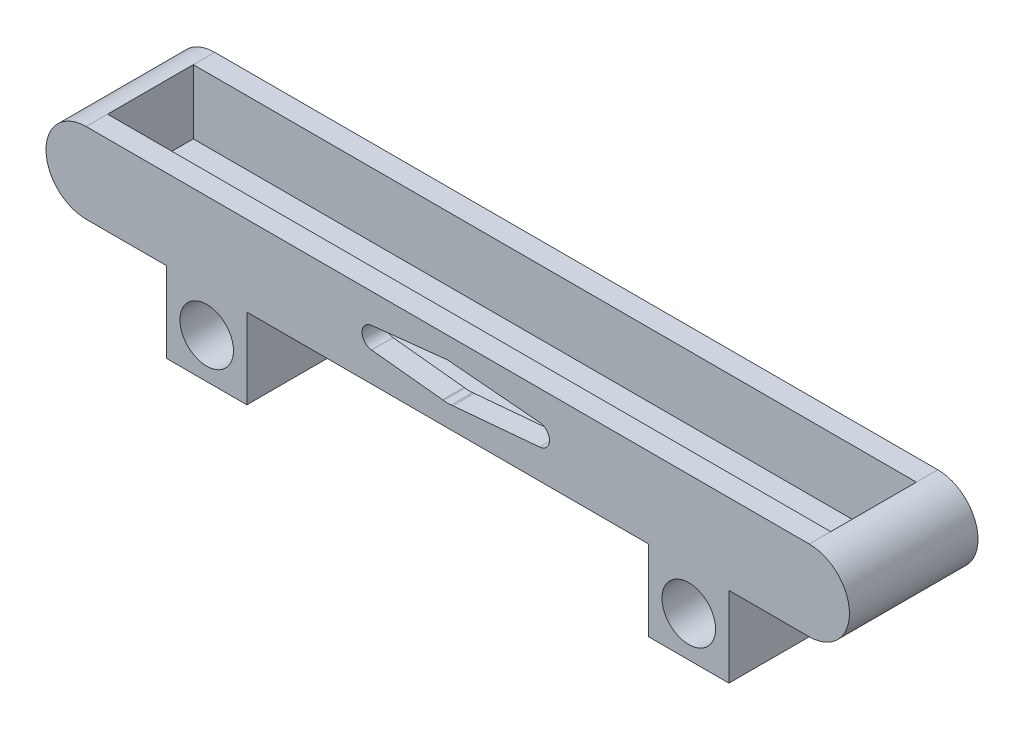
from build123d import *

# Parameters (mm, degrees)
SKETCH1_R           = 5
BOSS_EXTRUDE1_DEPTH = 4
BOSS_EXTRUDE2_START = -20
SKETCH1_4_R         = 5
BOSS_EXTRUDE2_DEPTH = 20
SKETCH2_W           = 135
SKETCH2_H           = 16
CUT_EXTRUDE1_DEPTH  = 12


with BuildPart() as part:
    # Sketch1 → Boss-Extrude1 (new body)
    with BuildSketch(Plane.XY):
        with BuildLine():
            Line((52.5, -7.5), (67.5, -7.5))
            ThreePointArc((67.5, -7.5), (75, 0), (67.5, 7.5))
            Line((67.5, 7.5), (-67.5, 7.5))
            ThreePointArc((-67.5, 7.5), (-75, 0), (-67.5, -7.5))
            Line((-67.5, -7.5), (-52.5, -7.5))
            Line((-52.5, -7.5), (-52.5, -22.5))
            Line((-52.5, -22.5), (-37.5, -22.5))
            Line((-37.5, -22.5), (-37.5, -7.5))
            Line((-37.5, -7.5), (37.5, -7.5))
            Line((37.5, -7.5), (37.5, -22.5))
            Line((37.5, -22.5), (52.5, -22.5))
            Line((52.5, -22.5), (52.5, -7.5))
        make_face()
        with BuildLine():
            Line((-14.211482552, 1.988787352), (-0.965077795, 3.3973761))
            ThreePointArc((-0.965077795, 3.3973761), (-0.860540111, 3.407937274), (-0.755897232, 3.417399505))
            ThreePointArc((-0.755897232, 3.417399505), (-0.049360306, 3.49965192), (0.65921534, 3.437358744))
            ThreePointArc((0.65921534, 3.437358744), (0.81309385, 3.427430851), (0.966800983, 3.415131426))
            Line((0.966800983, 3.415131426), (17.174893203, 1.992338417))
            ThreePointArc((17.174893203, 1.992338417), (19, 0), (17.174893203, -1.992338417))
            Line((17.174893203, -1.992338417), (0.966800983, -3.415131426))
            ThreePointArc((0.966800983, -3.415131426), (0.81309385, -3.427430851), (0.65921534, -3.437358744))
            ThreePointArc((0.65921534, -3.437358744), (-0.049360306, -3.49965192), (-0.755897232, -3.417399505))
            ThreePointArc((-0.755897232, -3.417399505), (-0.860540111, -3.407937274), (-0.965077795, -3.3973761))
            Line((-0.965077795, -3.3973761), (-14.211482552, -1.988787352))
            ThreePointArc((-14.211482552, -1.988787352), (-16, 0), (-14.211482552, 1.988787352))
        make_face(mode=Mode.SUBTRACT)
        with Locations((45, -15)):
            Circle(SKETCH1_R, mode=Mode.SUBTRACT)
        with Locations((-45, -15)):
            Circle(SKETCH1_R, mode=Mode.SUBTRACT)
    extrude(amount=BOSS_EXTRUDE1_DEPTH)

    # Sketch1_4 → Boss-Extrude2 (add)
    with BuildSketch(Plane.XY.offset(BOSS_EXTRUDE2_START)):
        with BuildLine():
            Line((52.5, -7.5), (67.5, -7.5))
            ThreePointArc((67.5, -7.5), (75, 0), (67.5, 7.5))
            Line((67.5, 7.5), (-67.5, 7.5))
            ThreePointArc((-67.5, 7.5), (-75, 0), (-67.5, -7.5))
            Line((-67.5, -7.5), (-52.5, -7.5))
            Line((-52.5, -7.5), (-52.5, -22.5))
            Line((-52.5, -22.5), (-37.5, -22.5))
            Line((-37.5, -22.5), (-37.5, -7.5))
            Line((-37.5, -7.5), (37.5, -7.5))
            Line((37.5, -7.5), (37.5, -22.5))
            Line((37.5, -22.5), (52.5, -22.5))
            Line((52.5, -22.5), (52.5, -7.5))
        make_face()
        with Locations((45, -15)):
            Circle(SKETCH1_4_R, mode=Mode.SUBTRACT)
        with Locations((-45, -15)):
            Circle(SKETCH1_4_R, mode=Mode.SUBTRACT)
    extrude(amount=BOSS_EXTRUDE2_DEPTH)

    # Sketch2 → Cut-Extrude1 (cut)
    with BuildSketch(Plane(origin=(0, 7.5, 0), x_dir=(1, 0, 0), z_dir=(0, 1, 0))):
        with Locations((0, 8)):
            Rectangle(SKETCH2_W, SKETCH2_H)
    extrude(amount=-CUT_EXTRUDE1_DEPTH, mode=Mode.SUBTRACT)


solid = part.part
